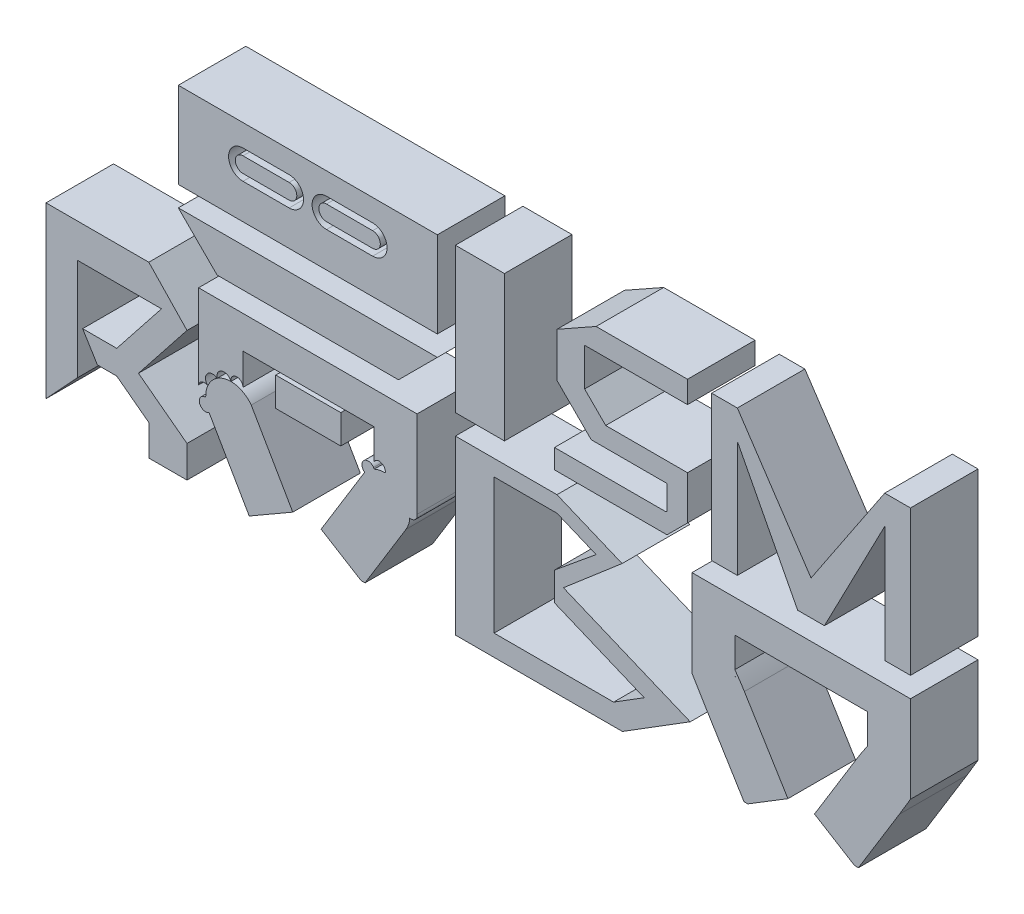
from build123d import *

# Parameters (mm, degrees)
BOSS_EXTRUDE2_DEPTH    = 25.4
BOSS_EXTRUDE2_2_DEPTH  = 25.4
BOSS_EXTRUDE2_3_DEPTH  = 25.4
SKETCH1_W              = 24.461502648
SKETCH1_H              = 10.87055051
BOSS_EXTRUDE2_4_DEPTH  = 25.4
BOSS_EXTRUDE2_5_DEPTH  = 25.4
BOSS_EXTRUDE2_6_DEPTH  = 25.4
BOSS_EXTRUDE2_7_DEPTH  = 25.4
SKETCH1_W_2            = 97.40937404
SKETCH1_H_2            = 32.313406886
BOSS_EXTRUDE2_8_DEPTH  = 25.4
BOSS_EXTRUDE2_9_DEPTH  = 25.4
BOSS_EXTRUDE2_10_DEPTH = 25.4
SKETCH1_W_3            = 18.443976291
SKETCH1_H_3            = 54.528233079
BOSS_EXTRUDE2_11_DEPTH = 25.4
BOSS_EXTRUDE2_12_DEPTH = 25.4
BOSS_EXTRUDE2_13_DEPTH = 25.4


with BuildPart() as part:
    # Sketch1 → Boss-Extrude2 (new body)
    with BuildSketch(Plane.XY):
        Polygon((-108.172530118, -11.93518958), (-96.26010229, 0.884070844), (-96.26010229, 39.060533562), (-64.726825967, 39.060533562), (-81.565077277, 17.772573776), (-94.386884579, 17.772573776), (-88.841643973, 8.742184939), (-81.585901967, 8.742184939), (-69.36107171, -0.45860836), (-69.36107171, -11.93518958), (-55.143012689, -11.93518958), (-55.143012689, 0), (-73.395926297, 13.737719189), (-55.143012689, 36.814182636), (-69.510757828, 51.854310106), (-108.172530118, 51.854310106), align=None)
    extrude(amount=BOSS_EXTRUDE2_DEPTH)


with BuildPart() as body_2:
    # Sketch1 → Boss-Extrude2 2 (new body)
    with BuildSketch(Plane.XY):
        with BuildLine():
            Line((-46.838728316, 14.208343836), (-31.744752261, -11.93518958))
            Line((-31.744752261, -11.93518958), (-15.366651823, -2.479288883))
            Line((-15.366651823, -2.479288883), (-30.990670753, 24.582305721))
            ThreePointArc((-30.990670753, 24.582305721), (-34.348326386, 27.418492639), (-38.623947508, 28.436761569))
            ThreePointArc((-38.623947508, 28.436761569), (-41.334535763, 28.041229116), (-43.819070994, 26.887617701))
            ThreePointArc((-43.819070994, 26.887617701), (-45.870352162, 25.072134244), (-47.317310012, 22.746183344))
            ThreePointArc((-47.317310012, 22.746183344), (-47.945269778, 20.708927541), (-48.102408011, 18.58288609))
            ThreePointArc((-48.102408011, 18.58288609), (-48.349430213, 18.547497946), (-48.598838642, 18.539268436))
            ThreePointArc((-48.598838642, 18.539268436), (-50.349964463, 15.304480473), (-46.838728316, 14.208343836))
        make_face()
    extrude(amount=BOSS_EXTRUDE2_2_DEPTH)


with BuildPart() as body_3:
    # Sketch1 → Boss-Extrude2 3 (new body)
    with BuildSketch(Plane.XY):
        with BuildLine():
            ThreePointArc((27.235458411, 13.228090155), (28.189211283, 15.313902664), (28.614455488, 17.567660798))
            ThreePointArc((28.614455488, 17.567660798), (28.863494696, 17.552274854), (29.109558058, 17.510921785))
            ThreePointArc((29.109558058, 17.510921785), (30.855913684, 18.309898726), (31.375476852, 20.158729772))
            Line((31.375476852, 20.158729772), (31.375476852, 52.886273929))
            Line((31.375476852, 52.886273929), (-50.793897188, 52.886273929))
            Line((-50.793897188, 52.886273929), (-50.793897188, 21.246110341))
            ThreePointArc((-50.793897188, 21.246110341), (-49.454250903, 22.920056612), (-47.317310012, 22.746183344))
            ThreePointArc((-47.317310012, 22.746183344), (-47.546826095, 26.488239395), (-43.819070994, 26.887617701))
            ThreePointArc((-43.819070994, 26.887617701), (-41.96163717, 30.144241829), (-38.623947508, 28.436761569))
            ThreePointArc((-38.623947508, 28.436761569), (-36.548711873, 31.073377711), (-34.08421851, 28.796401627))
            Line((-34.08421851, 28.796401627), (-34.08421851, 40.613707206))
            Line((-34.08421851, 40.613707206), (15.246800093, 40.613707206))
            Line((15.246800093, 40.613707206), (15.246800093, 29.343839534))
            ThreePointArc((15.246800093, 29.343839534), (18.009041678, 30.206446948), (19.400069174, 27.668906281))
            ThreePointArc((19.400069174, 27.668906281), (17.276133744, 27.485486089), (15.246800093, 26.832378436))
            ThreePointArc((15.246800093, 26.832378436), (15.121200281, 27.048010012), (15.019873113, 27.276056266))
            ThreePointArc((15.019873113, 27.276056266), (11.364167353, 27.683622468), (11.66746819, 24.017793311))
            Line((11.66746819, 24.017793311), (-4.711436484, -2.693039791))
            Line((-4.711436484, -2.693039791), (10.360726486, -11.93518958))
            Line((10.360726486, -11.93518958), (11.805503139, -11.93518958))
            Line((11.805503139, -11.93518958), (27.235458411, 13.228090155))
        make_face()
    extrude(amount=BOSS_EXTRUDE2_3_DEPTH)


with BuildPart() as body_4:
    # Sketch1 → Boss-Extrude2 4 (new body)
    with BuildSketch(Plane.XY):
        with Locations((-9.539545162, 33.52338424)):
            Rectangle(SKETCH1_W, SKETCH1_H)
    extrude(amount=BOSS_EXTRUDE2_4_DEPTH)


with BuildPart() as body_5:
    # Sketch1 → Boss-Extrude2 5 (new body)
    with BuildSketch(Plane.XY):
        Polygon((45.788811717, 52.886273929), (45.788811717, -11.93518958), (108.601620736, -11.93518958), (134.101452531, 3.965297599), (86.409473786, 23.78948382), (108.484058542, 42.706539224), (83.994191176, 52.886273929), align=None)
        Polygon((60.33922231, 46.847651943), (83.994191176, 46.847651943), (98.705457979, 40.732600726), (83.066671585, 27.87507369), (83.066671585, 17.189671733), (116.813298843, 3.162167722), (105.292592369, -4.021599098), (60.33922231, -4.021599098), align=None, mode=Mode.SUBTRACT)
    extrude(amount=BOSS_EXTRUDE2_5_DEPTH)


with BuildPart() as body_6:
    # Sketch1 → Boss-Extrude2 6 (new body)
    with BuildSketch(Plane.XY):
        with BuildLine():
            Line((134.757866317, 20.158729772), (138.897884758, 13.228090155))
            Line((138.897884758, 13.228090155), (154.327840031, -11.93518958))
            Line((154.327840031, -11.93518958), (155.772616684, -11.93518958))
            Line((155.772616684, -11.93518958), (170.844779653, -2.693039791))
            Line((170.844779653, -2.693039791), (154.46587498, 24.017793311))
            ThreePointArc((154.46587498, 24.017793311), (152.731676351, 26.718092847), (150.886543077, 29.343839534))
            Line((150.886543077, 29.343839534), (150.886543077, 40.613707206))
            Line((150.886543077, 40.613707206), (200.798563598, 40.613707206))
            Line((200.798563598, 40.613707206), (200.798563598, 29.343839534))
            ThreePointArc((200.798563598, 29.343839534), (198.953430323, 26.718092847), (197.219231694, 24.017793311))
            Line((197.219231694, 24.017793311), (180.840327021, -2.693039791))
            Line((180.840327021, -2.693039791), (195.91248999, -11.93518958))
            Line((195.91248999, -11.93518958), (197.357266644, -11.93518958))
            Line((197.357266644, -11.93518958), (212.787221916, 13.228090155))
            Line((212.787221916, 13.228090155), (216.927240357, 20.158729772))
            Line((216.927240357, 20.158729772), (216.927240357, 52.886273929))
            Line((216.927240357, 52.886273929), (134.757866317, 52.886273929))
            Line((134.757866317, 52.886273929), (134.757866317, 20.158729772))
        make_face()
        with BuildLine():
            ThreePointArc((137.518887681, 17.567660798), (137.27288843, 17.525748302), (137.023785111, 17.510921785))
            ThreePointArc((137.023785111, 17.510921785), (137.269848473, 17.552274854), (137.518887681, 17.567660798))
        make_face(mode=Mode.SUBTRACT)
        with BuildLine():
            ThreePointArc((151.113470057, 27.276056266), (151.012142888, 27.048010012), (150.886543077, 26.832378436))
            ThreePointArc((150.886543077, 26.832378436), (150.988371565, 27.060168281), (151.113470057, 27.276056266))
        make_face(mode=Mode.SUBTRACT)
    extrude(amount=BOSS_EXTRUDE2_6_DEPTH)


with BuildPart() as body_7:
    # Sketch1 → Boss-Extrude2 7 (new body)
    with BuildSketch(Plane.XY):
        Polygon((-58.413897188, 75.101100122), (-43.819070994, 60.506273929), (24.400650659, 60.506273929), (38.995476852, 75.101100122), align=None)
    extrude(amount=BOSS_EXTRUDE2_7_DEPTH)


with BuildPart() as body_8:
    # Sketch1 → Boss-Extrude2 8 (new body)
    with BuildSketch(Plane.XY):
        with Locations((-9.709210168, 98.877803565)):
            Rectangle(SKETCH1_W_2, SKETCH1_H_2)
        with BuildLine():
            ThreePointArc((-34.08421851, 95.909460513), (-39.507739158, 101.332981161), (-34.08421851, 106.756501809))
            Line((-34.08421851, 106.756501809), (-16.742394345, 106.756501809))
            ThreePointArc((-16.742394345, 106.756501809), (-11.318873697, 101.332981161), (-16.742394345, 95.909460513))
            Line((-16.742394345, 95.909460513), (-34.08421851, 95.909460513))
        make_face(mode=Mode.SUBTRACT)
        with BuildLine():
            ThreePointArc((14.665798175, 106.756501809), (20.089318823, 101.332981161), (14.665798175, 95.909460513))
            Line((14.665798175, 95.909460513), (-2.67602599, 95.909460513))
            ThreePointArc((-2.67602599, 95.909460513), (-8.099546638, 101.332981161), (-2.67602599, 106.756501809))
            Line((-2.67602599, 106.756501809), (14.665798175, 106.756501809))
        make_face(mode=Mode.SUBTRACT)
    extrude(amount=BOSS_EXTRUDE2_8_DEPTH)


with BuildPart() as body_9:
    # Sketch1 → Boss-Extrude2 9 (new body)
    with BuildSketch(Plane.XY):
        with BuildLine():
            Line((-16.742394345, 104.216501809), (-34.08421851, 104.216501809))
            ThreePointArc((-34.08421851, 104.216501809), (-36.967739158, 101.332981161), (-34.08421851, 98.449460513))
            Line((-34.08421851, 98.449460513), (-16.742394345, 98.449460513))
            ThreePointArc((-16.742394345, 98.449460513), (-13.858873697, 101.332981161), (-16.742394345, 104.216501809))
        make_face()
    extrude(amount=BOSS_EXTRUDE2_9_DEPTH)


with BuildPart() as body_10:
    # Sketch1 → Boss-Extrude2 10 (new body)
    with BuildSketch(Plane.XY):
        with BuildLine():
            ThreePointArc((14.665798175, 98.449460513), (17.549318823, 101.332981161), (14.665798175, 104.216501809))
            Line((14.665798175, 104.216501809), (-2.67602599, 104.216501809))
            ThreePointArc((-2.67602599, 104.216501809), (-5.559546638, 101.332981161), (-2.67602599, 98.449460513))
            Line((-2.67602599, 98.449460513), (14.665798175, 98.449460513))
        make_face()
    extrude(amount=BOSS_EXTRUDE2_10_DEPTH)


with BuildPart() as body_11:
    # Sketch1 → Boss-Extrude2 11 (new body)
    with BuildSketch(Plane.XY):
        with Locations((55.010799863, 87.770390469)):
            Rectangle(SKETCH1_W_3, SKETCH1_H_3)
    extrude(amount=BOSS_EXTRUDE2_11_DEPTH)


with BuildPart() as body_12:
    # Sketch1 → Boss-Extrude2 12 (new body)
    with BuildSketch(Plane.XY):
        Polygon((83.066671585, 67.800770925), (83.066671585, 60.506273929), (125.371409153, 60.506273929), (133.076133815, 68.210998592), (133.076133815, 84.583967788), (102.317567308, 84.583967788), (94.387045713, 92.514489383), (94.387045713, 106.756501809), (133.076133815, 106.756501809), (133.076133815, 115.034507008), (98.705457979, 115.034507008), (83.994191176, 106.756501809), (83.994191176, 90.097550177), (96.863406967, 77.228334386), (125.371409153, 77.228334386), (125.371409153, 68.210998592), (124.961181486, 67.800770925), align=None)
    extrude(amount=BOSS_EXTRUDE2_12_DEPTH)


with BuildPart() as body_13:
    # Sketch1 → Boss-Extrude2 13 (new body)
    with BuildSketch(Plane.XY):
        Polygon((142.154606016, 115.034507008), (142.154606016, 60.506273929), (151.823190987, 60.506273929), (151.823190987, 104.216501809), (174.508171362, 60.506273929), (184.573675011, 60.506273929), (207.258655386, 104.216501809), (207.258655386, 60.506273929), (216.927240357, 60.506273929), (216.927240357, 115.034507008), (207.258655386, 115.034507008), (179.540923187, 73.518123702), (151.823190987, 115.034507008), align=None)
    extrude(amount=BOSS_EXTRUDE2_13_DEPTH)


solid = Compound([part.part, body_2.part, body_3.part, body_4.part, body_5.part, body_6.part, body_7.part, body_8.part, body_9.part, body_10.part, body_11.part, body_12.part, body_13.part])
